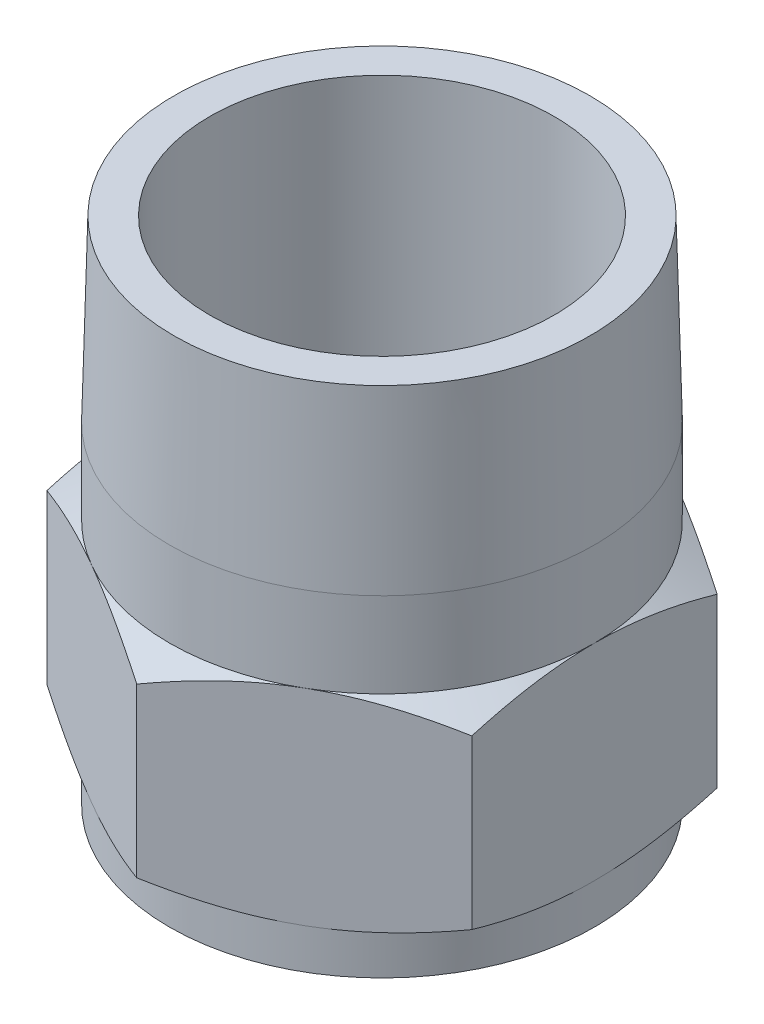
from build123d import *

# Parameters (mm, degrees)
SKETCH2_R           = 19.25
BOSS_EXTRUDE1_DEPTH = 57


with BuildPart() as part:
    # Sketch2 → Boss-Extrude1 (new body)
    with BuildSketch(Plane(origin=(0, 0, 0), x_dir=(1, 0, 0), z_dir=(0, 1, 0))):
        Polygon((0, 27.424137787), (-23.75, 13.712068893), (-23.75, -13.712068893), (0, -27.424137787), (23.75, -13.712068893), (23.75, 13.712068893), align=None)
        Circle(SKETCH2_R, mode=Mode.SUBTRACT)
    extrude(amount=BOSS_EXTRUDE1_DEPTH)

    # Sketch3 → Cut-Revolve2 (revolve, cut)
    with BuildSketch(Plane.XY):
        Polygon((0, 57), (-23.25, 57), (-23.75, 37), (-23.75, 27.5), (-33.75, 21.726497308), (-33.75, 10.273502692), (-23.75, 4.5), (-23.75, 0), (-45.690595107, 0), (-45.690595107, 61.224990586), (0, 61.224990586), align=None)
    revolve(axis=Axis((0, 64.286240116, 0), (0, -1, 0)), mode=Mode.SUBTRACT)


solid = part.part
